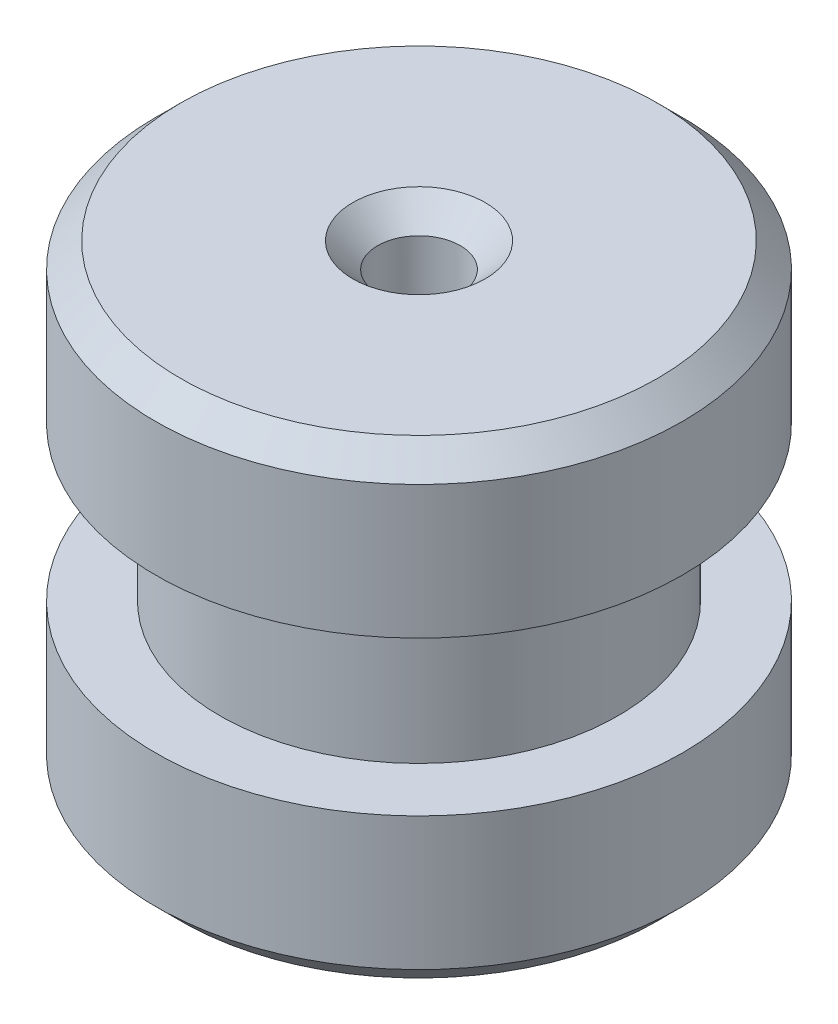
from build123d import *

# Parameters (mm, degrees)
SKETCH2_R          = 1.2446
CUT_EXTRUDE1_DEPTH = 15.16
SKETCH4_R          = 2.5
CUT_EXTRUDE3_DEPTH = 6
CHAMFER1_SIZE      = 0.75


with BuildPart() as part:
    # Sketch1 → Revolve1 (revolve)
    with BuildSketch(Plane.XY):
        Polygon((0, 14.16), (0, 0), (7.9375, 0), (7.9375, 4.76), (6, 4.76), (6, 9.4), (7.9375, 9.4), (7.9375, 14.16), align=None)
    revolve(axis=Axis((0, 14.16, 0), (0, -1, 0)))

    # Sketch2 → Cut-Extrude1 (cut, through all)
    with BuildSketch(Plane(origin=(0, 14.16, 0), x_dir=(1, 0, 0), z_dir=(0, 1, 0))):
        Circle(SKETCH2_R)
    extrude(amount=-CUT_EXTRUDE1_DEPTH, mode=Mode.SUBTRACT)

    # Sketch4 → Cut-Extrude3 (cut)
    with BuildSketch(Plane.XZ):
        Circle(SKETCH4_R)
    extrude(amount=-CUT_EXTRUDE3_DEPTH, mode=Mode.SUBTRACT)

    # Chamfer1
    chamfer1_edges = [part.edges().sort_by_distance(p)[0] for p in [
        (-1.2446, 14.16, 0),
        (-7.9375, 14.16, 0),
        (-7.9375, 0, 0),
    ]]
    chamfer(chamfer1_edges, length=CHAMFER1_SIZE)


solid = part.part
